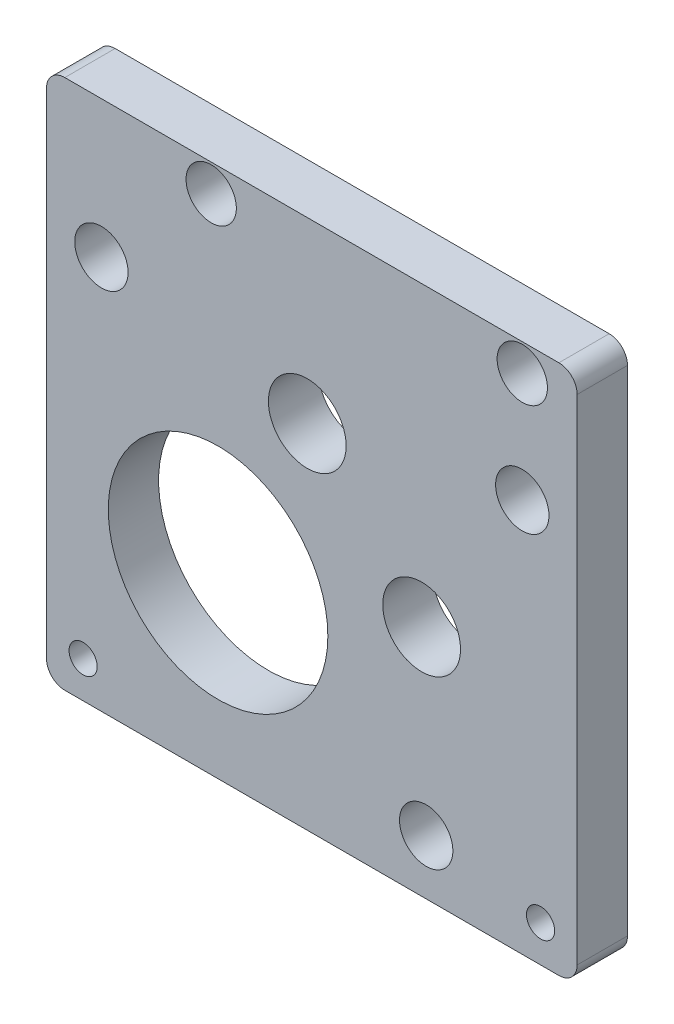
from build123d import *

# Parameters (mm, degrees)
SKETCH1_R           = 4.25
SKETCH1_R_2         = 1.53775
SKETCH1_R_3         = 2.916
SKETCH1_R_4         = 2.75
SKETCH1_R_5         = 12
BOSS_EXTRUDE1_DEPTH = 5.5


with BuildPart() as part:
    # Sketch1 → Boss-Extrude1 (new body)
    with BuildSketch(Plane.XY):
        with BuildLine():
            Line((29, -27), (29, 27))
            ThreePointArc((29, 27), (28.414213562, 28.414213562), (27, 29))
            Line((27, 29), (-27, 29))
            ThreePointArc((-27, 29), (-28.414213562, 28.414213562), (-29, 27))
            Line((-29, 27), (-29, -27))
            ThreePointArc((-29, -27), (-28.414213562, -28.414213562), (-27, -29))
            Line((-27, -29), (27, -29))
            ThreePointArc((27, -29), (28.414213562, -28.414213562), (29, -27))
        make_face()
        with Locations((-0.5, 9.5)):
            Circle(SKETCH1_R, mode=Mode.SUBTRACT)
        with Locations((25, -25)):
            Circle(SKETCH1_R_2, mode=Mode.SUBTRACT)
        with Locations((12.5, -23)):
            Circle(SKETCH1_R_3, mode=Mode.SUBTRACT)
        with Locations((-11, 26)):
            Circle(SKETCH1_R_4, mode=Mode.SUBTRACT)
        with Locations((-10.25, -9.5)):
            Circle(SKETCH1_R_5, mode=Mode.SUBTRACT)
        with Locations((23, 26)):
            Circle(SKETCH1_R_4, mode=Mode.SUBTRACT)
        with Locations((23, 14)):
            Circle(SKETCH1_R_3, mode=Mode.SUBTRACT)
        with Locations((-23, 14)):
            Circle(SKETCH1_R_3, mode=Mode.SUBTRACT)
        with Locations((-25, -25)):
            Circle(SKETCH1_R_2, mode=Mode.SUBTRACT)
        with Locations((12, -3.5)):
            Circle(SKETCH1_R, mode=Mode.SUBTRACT)
    extrude(amount=BOSS_EXTRUDE1_DEPTH)


solid = part.part
